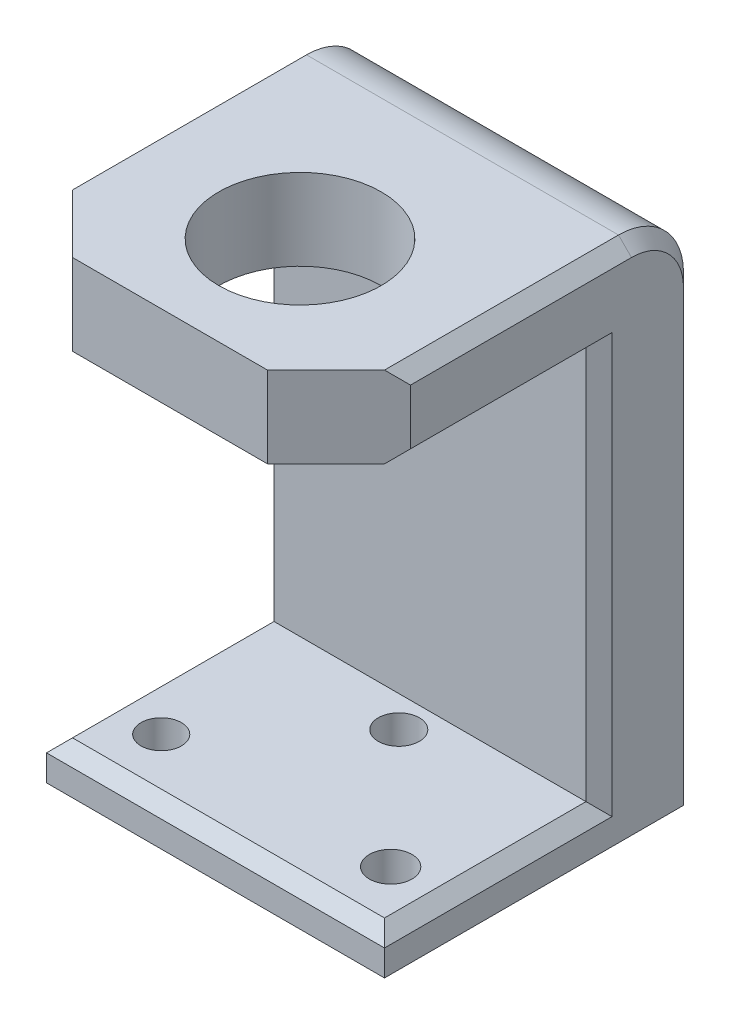
from build123d import *

# Parameters (mm, degrees)
SKETCH1_W           = 66.04
SKETCH1_H           = 60.96
SKETCH1_R           = 3.949643495
SKETCH1_R_2         = 4.169884911
SKETCH1_R_3         = 4.009399438
BOSS_EXTRUDE1_DEPTH = 7.62
SKETCH3_W           = 66.04
SKETCH3_H           = 19.05
BOSS_EXTRUDE2_DEPTH = 92.71
SKETCH4_W           = 66.04
SKETCH4_H           = 15.875
BOSS_EXTRUDE3_DEPTH = 50.8
SKETCH5_R           = 15.875
CUT_EXTRUDE2_DEPTH  = 15.875
FILLET1_R           = 12.7
CHAMFER2_SIZE       = 2.54
CHAMFER3_SIZE       = 13.97


with BuildPart() as part:
    # Sketch1 → Boss-Extrude1 (new body)
    with BuildSketch(Plane(origin=(0, 0, 0), x_dir=(1, 0, 0), z_dir=(0, 1, 0))):
        with Locations((-10.475534623, -61.030768925)):
            Rectangle(SKETCH1_W, SKETCH1_H)
        with Locations((-32.891034623, -79.700340115)):
            Circle(SKETCH1_R, mode=Mode.SUBTRACT)
        with Locations((11.939965377, -79.700340115)):
            Circle(SKETCH1_R_2, mode=Mode.SUBTRACT)
        with Locations((-10.475534623, -55.697340115)):
            Circle(SKETCH1_R_3, mode=Mode.SUBTRACT)
    extrude(amount=BOSS_EXTRUDE1_DEPTH)

    # Sketch3 → Boss-Extrude2 (add)
    with BuildSketch(Plane(origin=(0, 7.62, 0), x_dir=(1, 0, 0), z_dir=(0, 1, 0))):
        with Locations((-10.475534623, -40.075768925)):
            Rectangle(SKETCH3_W, SKETCH3_H)
    extrude(amount=BOSS_EXTRUDE2_DEPTH)

    # Sketch4 → Boss-Extrude3 (add)
    with BuildSketch(Plane.XY.offset(49.600768925)):
        with Locations((-10.475534623, 92.3925)):
            Rectangle(SKETCH4_W, SKETCH4_H)
    extrude(amount=BOSS_EXTRUDE3_DEPTH)

    # Sketch5 → Cut-Extrude2 (cut)
    with BuildSketch(Plane(origin=(0, 100.33, 0), x_dir=(1, 0, 0), z_dir=(0, 1, 0))):
        with Locations((-10.475534623, -75.000768925)):
            Circle(SKETCH5_R)
    extrude(amount=-CUT_EXTRUDE2_DEPTH, mode=Mode.SUBTRACT)

    # Fillet1
    fillet1_edges = [part.edges().sort_by_distance(p)[0] for p in [
        (-10.475534623, 100.33, 30.550768925),
    ]]
    fillet(fillet1_edges, radius=FILLET1_R)

    # Chamfer2
    chamfer2_edges = [part.edges().sort_by_distance(p)[0] for p in [
        (-43.495534623, 7.62, 70.555768925),
        (22.544465377, 100.33, 71.825768925),
        (22.544465377, 46.0375, 49.600768925),
        (-43.495534623, 46.0375, 49.600768925),
        (-10.475534623, 7.62, 91.510768925),
        (-43.495534623, 84.455, 75.000768925),
        (22.544465377, 84.455, 75.000768925),
        (-43.495534623, 100.33, 71.825768925),
        (-43.495534623, 43.815, 30.550768925),
        (-43.495534623, 96.610256121, 34.270512804),
        (22.544465377, 43.815, 30.550768925),
        (22.544465377, 96.610256121, 34.270512804),
        (22.544465377, 7.62, 70.555768925),
    ]]
    chamfer(chamfer2_edges, length=CHAMFER2_SIZE)

    # Chamfer3
    chamfer3_edges = [part.edges().sort_by_distance(p)[0] for p in [
        (-43.495534623, 92.3925, 100.400768925),
        (22.544465377, 92.3925, 100.400768925),
    ]]
    chamfer(chamfer3_edges, length=CHAMFER3_SIZE)


solid = part.part
